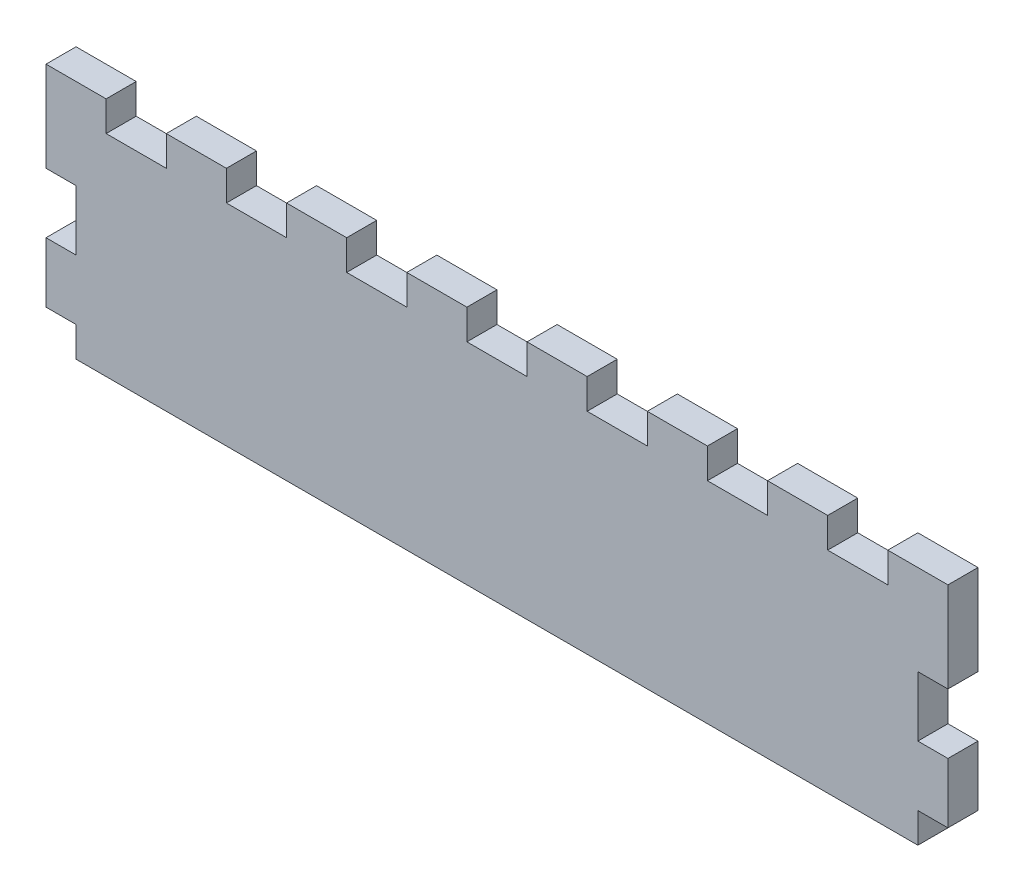
from build123d import *

# Parameters (mm, degrees)
SKETCH1_W           = 190.5
SKETCH1_H           = 50.8
BOSS_EXTRUDE1_DEPTH = 6.35
SKETCH2_W           = 6.35
SKETCH2_H           = 12.7
CUT_EXTRUDE1_DEPTH  = 7.35
SKETCH3_W           = 6.35
SKETCH3_H           = 6.35
CUT_EXTRUDE2_DEPTH  = 7.35
SKETCH4_W           = 12.7
SKETCH4_H           = 6.35
CUT_EXTRUDE3_DEPTH  = 7.35
LPATTERN1_COUNT     = 7
LPATTERN1_PITCH     = 25.4


with BuildPart() as part:
    # Sketch1 → Boss-Extrude1 (new body)
    with BuildSketch(Plane.XY):
        Rectangle(SKETCH1_W, SKETCH1_H)
    extrude(amount=BOSS_EXTRUDE1_DEPTH)

    # Sketch2 → Cut-Extrude1 (cut, through all)
    with BuildSketch(Plane.XY.offset(6.35)):
        with Locations((-92.075, 0)):
            Rectangle(SKETCH2_W, SKETCH2_H)
    cut_extrude1 = extrude(amount=-CUT_EXTRUDE1_DEPTH, mode=Mode.SUBTRACT)

    # Sketch3 → Cut-Extrude2 (cut, through all)
    with BuildSketch(Plane.XY.offset(6.35)):
        with Locations((-92.075, -22.225)):
            Rectangle(SKETCH3_W, SKETCH3_H)
    cut_extrude2 = extrude(amount=-CUT_EXTRUDE2_DEPTH, mode=Mode.SUBTRACT)

    # Mirror1: Cut-Extrude2 across plane
    add(cut_extrude2.mirror(Plane(origin=(0, 0, 0), x_dir=(0, 0, 1), z_dir=(1, 0, 0))), mode=Mode.SUBTRACT)

    # Mirror2: Cut-Extrude1 across plane
    add(cut_extrude1.mirror(Plane(origin=(0, 0, 0), x_dir=(0, 0, 1), z_dir=(1, 0, 0))), mode=Mode.SUBTRACT)

    # Sketch4 → Cut-Extrude3 (cut, through all)
    with BuildSketch(Plane.XY.offset(6.35)):
        with Locations((-76.2, 22.225)):
            Rectangle(SKETCH4_W, SKETCH4_H)
    cut_extrude3 = extrude(amount=-CUT_EXTRUDE3_DEPTH, mode=Mode.SUBTRACT)

    # LPattern1: Cut-Extrude3 ×7
    with Locations(*[(i * LPATTERN1_PITCH, 0, 0) for i in range(1, LPATTERN1_COUNT)]):
        add(cut_extrude3, mode=Mode.SUBTRACT)


solid = part.part
